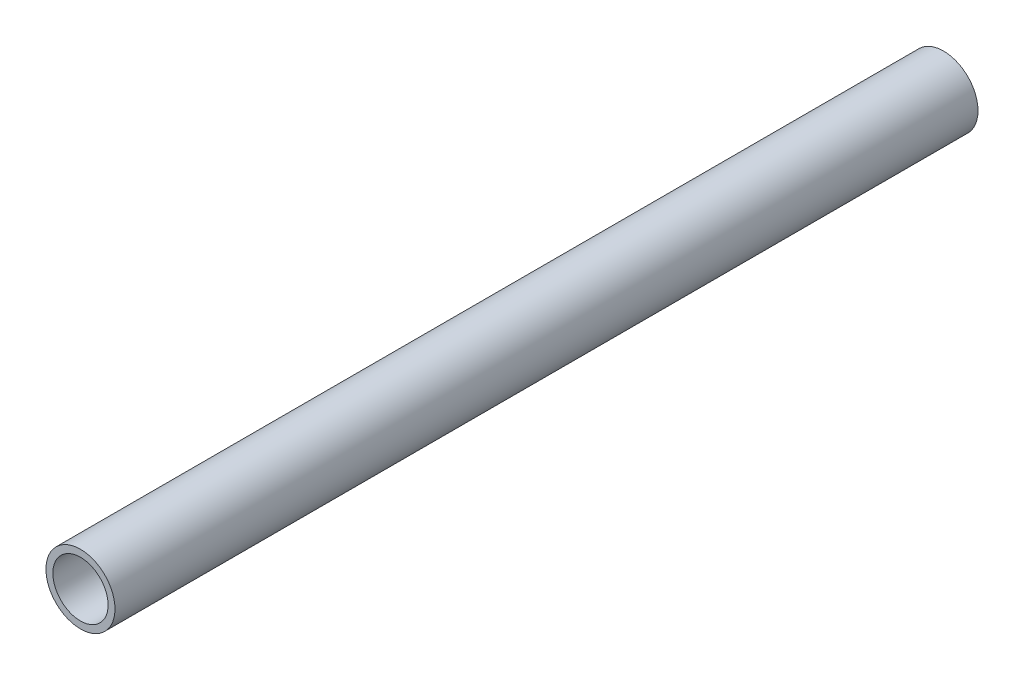
from build123d import *

# Parameters (mm, degrees)
SKETCH1_R           = 12.7
SKETCH1_R_2         = 10.16
BOSS_EXTRUDE1_DEPTH = 317.5


with BuildPart() as part:
    # Sketch1 → Boss-Extrude1 (new body)
    with BuildSketch(Plane.XY):
        Circle(SKETCH1_R)
        Circle(SKETCH1_R_2, mode=Mode.SUBTRACT)
    extrude(amount=BOSS_EXTRUDE1_DEPTH)


solid = part.part
